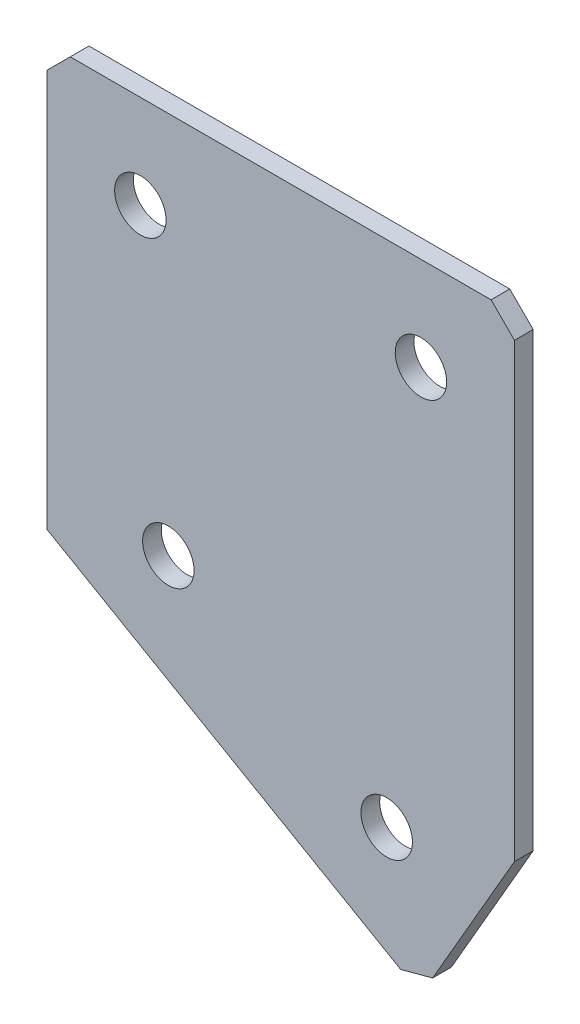
from build123d import *

# Parameters (mm, degrees)
EXTRUDE_1_DEPTH   = 2
HOLE_WIZARD_M51_D = 5.5
CHAMFER_1_SIZE    = 2.5


with BuildPart() as part:
    # Эскиз3 → Бобышка-Вытянуть1 (new body)
    with BuildSketch(Plane(origin=(0, 0, 0), x_dir=(1, 0, 0), z_dir=(0, 0, -1))):
        Polygon((0, 0), (50, 0), (50, 50.773502692), (40, 68.094010768), (0, 45), align=None)
    extrude(amount=EXTRUDE_1_DEPTH)

    # Отверстие с зазором M51 (through all)
    with Locations(Plane(origin=(0, 0, -2), x_dir=(1, 0, 0), z_dir=(0, 0, -1))):
        with Locations((10, 10), (40, 10), (12.990381057, 40.952994616), (36.339745962, 54.43375673)):
            Hole(HOLE_WIZARD_M51_D / 2)

    # Фаска1
    chamfer_1_edges = [part.edges().sort_by_distance(p)[0] for p in [
        (40, -68.094010768, -1),
        (50, 0, -1),
        (0, 0, -1),
    ]]
    chamfer(chamfer_1_edges, length=CHAMFER_1_SIZE)


solid = part.part
